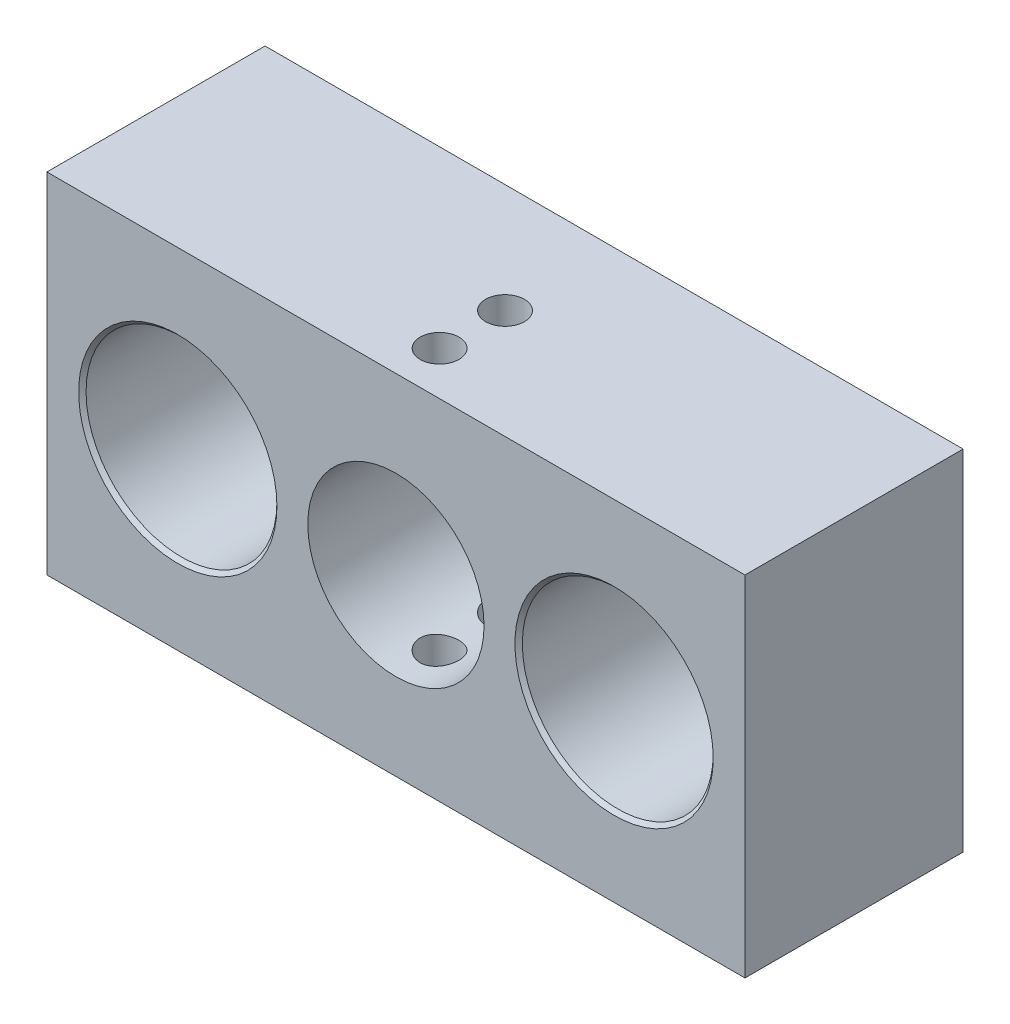
from build123d import *

# Parameters (mm, degrees)
SKETCH1_W                                     = 40.64
SKETCH1_H                                     = 20.32
BOSS_EXTRUDE2_DEPTH                           = 12.7
CBORE_FOR_1_4_SOCKET_HEAD_CAP_SCREW1_AT_COUNT = 2
CBORE_FOR_1_4_SOCKET_HEAD_CAP_SCREW1_AT_PITCH = 25.4
HOLE1_D                                       = 10.2616
HOLE1_DEPTH                                   = 9.525
F_4_40_TAPPED_HOLE1_D                         = 2.2606


with BuildPart() as part:
    # Sketch1 → Boss-Extrude2 (new body)
    with BuildSketch(Plane.XY):
        with Locations((20.32, 10.16)):
            Rectangle(SKETCH1_W, SKETCH1_H)
    extrude(amount=BOSS_EXTRUDE2_DEPTH)

    # Sketch3 → CBORE for 1/4 Socket Head Cap Screw1 (revolve, cut)
    with BuildSketch(Plane(origin=(7.62, 10.16, 12.7), x_dir=(0, -1, 0), z_dir=(1, 0, 0))):
        Polygon((0, 0), (0, 12.7), (3.3782, 12.7), (3.3782, 9.525), (5.55625, 9.525), (5.55625, 0.2159), (5.77215, 0), align=None)
    cbore_for_1_4_socket_head_cap_screw1 = revolve(axis=Axis((7.62, 10.16, 19.05), (0, 0, -1)), mode=Mode.SUBTRACT)

    # CBORE for 1/4 Socket Head Cap Screw1 at: CBORE for 1/4 Socket Head Cap Screw1 ×2
    with Locations(*[(i * CBORE_FOR_1_4_SOCKET_HEAD_CAP_SCREW1_AT_PITCH, 0, 0) for i in range(1, CBORE_FOR_1_4_SOCKET_HEAD_CAP_SCREW1_AT_COUNT)]):
        add(cbore_for_1_4_socket_head_cap_screw1, mode=Mode.SUBTRACT)

    # Hole1
    with Locations(Plane.XY.offset(12.7)):
        with Locations((20.32, 10.16)):
            Hole(HOLE1_D / 2, depth=HOLE1_DEPTH)

    # #4-40 Tapped Hole1 (through all)
    with Locations(Plane(origin=(0, 20.32, 0), x_dir=(1, 0, 0), z_dir=(0, 1, 0))):
        with Locations((20.32, -10.16), (20.32, -6.35)):
            Hole(F_4_40_TAPPED_HOLE1_D / 2)


solid = part.part
